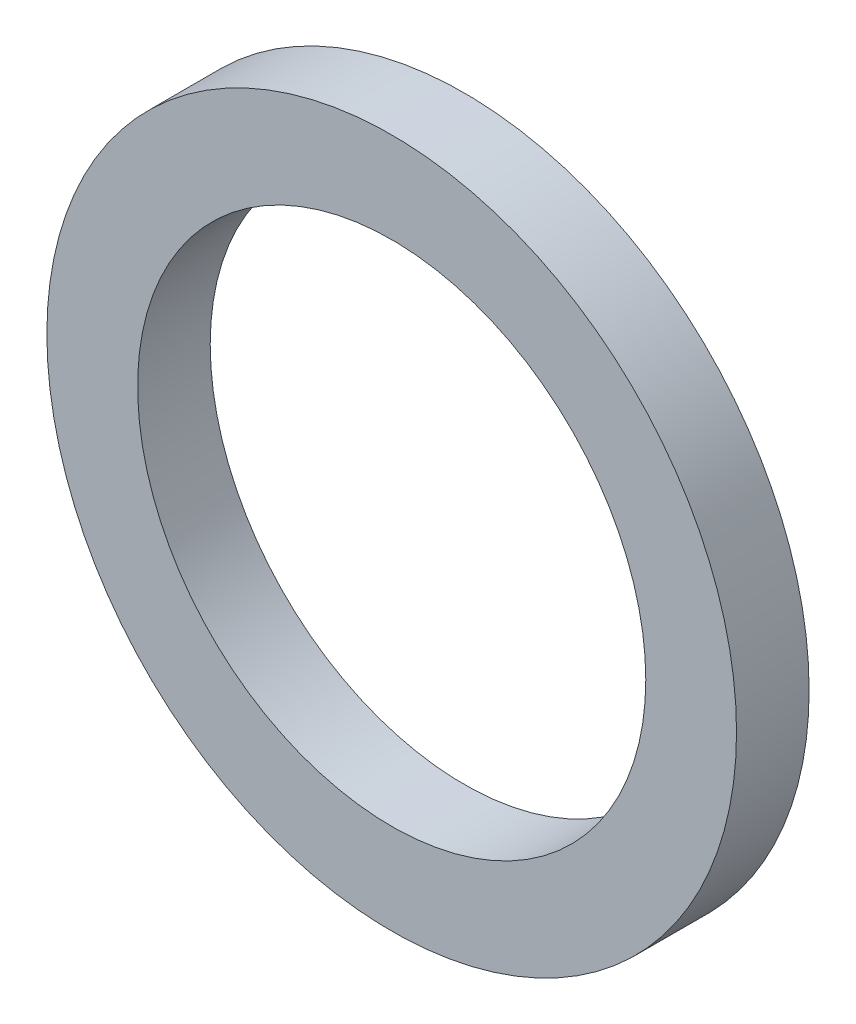
from build123d import *

# Parameters (mm, degrees)
ESQUISSE1_R                  = 48.5
BOSS_EXTRU_1_DEPTH           = 70
ESQUISSE2_R                  = 48.5
ESQUISSE2_R_2                = 47.5
ENL_V_MAT_EXTRU_1_DEPTH      = 10
ESQUISSE3_R                  = 35
ENL_V_MAT_EXTRU_2_DEPTH      = 71
ESQUISSE5_R                  = 45
ESQUISSE5_R_2                = 37
ENL_V_MAT_EXTRU_3_DEPTH      = 68
ESQUISSE6_W                  = 20
ESQUISSE6_H                  = 4.679506057
ENL_V_MAT_EXTRU_5_DEPTH      = 68
BOSS_EXTRU_2_DEPTH           = 10
ESQUISSE9_W                  = 97.082032755
ESQUISSE9_H                  = 83.812700188
ENL_V_MAT_EXTRU_6_DEPTH      = 49.5
ENL_V_MAT_EXTRU_6_DEPTH_BACK = 48.5


with BuildPart() as part:
    # Esquisse1 → Boss.-Extru.1 (new body)
    with BuildSketch(Plane.XY):
        Circle(ESQUISSE1_R)
    extrude(amount=BOSS_EXTRU_1_DEPTH)

    # Esquisse2 → Enlèv. mat.-Extru.1 (cut)
    with BuildSketch(Plane.XY.offset(70)):
        Circle(ESQUISSE2_R)
        Circle(ESQUISSE2_R_2, mode=Mode.SUBTRACT)
    extrude(amount=-ENL_V_MAT_EXTRU_1_DEPTH, mode=Mode.SUBTRACT)

    # Esquisse3 → Enlèv. mat.-Extru.2 (cut, through all)
    with BuildSketch(Plane.XY.offset(70)):
        Circle(ESQUISSE3_R)
    extrude(amount=-ENL_V_MAT_EXTRU_2_DEPTH, mode=Mode.SUBTRACT)

    # Esquisse5 → Enlèv. mat.-Extru.3 (cut)
    with BuildSketch(Plane(origin=(0, 0, 0), x_dir=(-1, 0, 0), z_dir=(0, 0, -1))):
        Circle(ESQUISSE5_R)
        Circle(ESQUISSE5_R_2, mode=Mode.SUBTRACT)
    extrude(amount=-ENL_V_MAT_EXTRU_3_DEPTH, mode=Mode.SUBTRACT)

    # Esquisse6 → Enlèv. mat.-Extru.5 (cut)
    with BuildSketch(Plane(origin=(0, 0, 0), x_dir=(-1, 0, 0), z_dir=(0, 0, -1))):
        with Locations((0, -46.214574966)):
            Rectangle(ESQUISSE6_W, ESQUISSE6_H)
    extrude(amount=-ENL_V_MAT_EXTRU_5_DEPTH, mode=Mode.SUBTRACT)

    # Esquisse8 → Boss.-Extru.2 (add)
    with BuildSketch(Plane(origin=(0, 0, 0), x_dir=(-1, 0, 0), z_dir=(0, 0, -1))):
        with BuildLine():
            ThreePointArc((34.294678888, -34.294678888), (48.5, 0), (34.294678888, 34.294678888))
            Line((34.294678888, 34.294678888), (31.819805153, 31.819805153))
            ThreePointArc((31.819805153, 31.819805153), (45, 0), (31.819805153, -31.819805153))
            Line((31.819805153, -31.819805153), (34.294678888, -34.294678888))
        make_face()
        with BuildLine():
            ThreePointArc((-34.294678888, -34.294678888), (-48.5, 0), (-34.294678888, 34.294678888))
            Line((-34.294678888, 34.294678888), (-31.819805153, 31.819805153))
            ThreePointArc((-31.819805153, 31.819805153), (-45, 0), (-31.819805153, -31.819805153))
            Line((-31.819805153, -31.819805153), (-34.294678888, -34.294678888))
        make_face()
    extrude(amount=BOSS_EXTRU_2_DEPTH)

    # Esquisse9 → Enlèv. mat.-Extru.6 (cut, two sides)
    with BuildSketch(Plane(origin=(0, 0, 0), x_dir=(1, 0, 0), z_dir=(0, 1, 0))) as enl_v_mat_extru_6_sk:
        with Locations((0.041016378, -18.093649906)):
            Rectangle(ESQUISSE9_W, ESQUISSE9_H)
    extrude(amount=ENL_V_MAT_EXTRU_6_DEPTH, mode=Mode.SUBTRACT)
    extrude(enl_v_mat_extru_6_sk.sketch, amount=-ENL_V_MAT_EXTRU_6_DEPTH_BACK, mode=Mode.SUBTRACT)


solid = part.part
